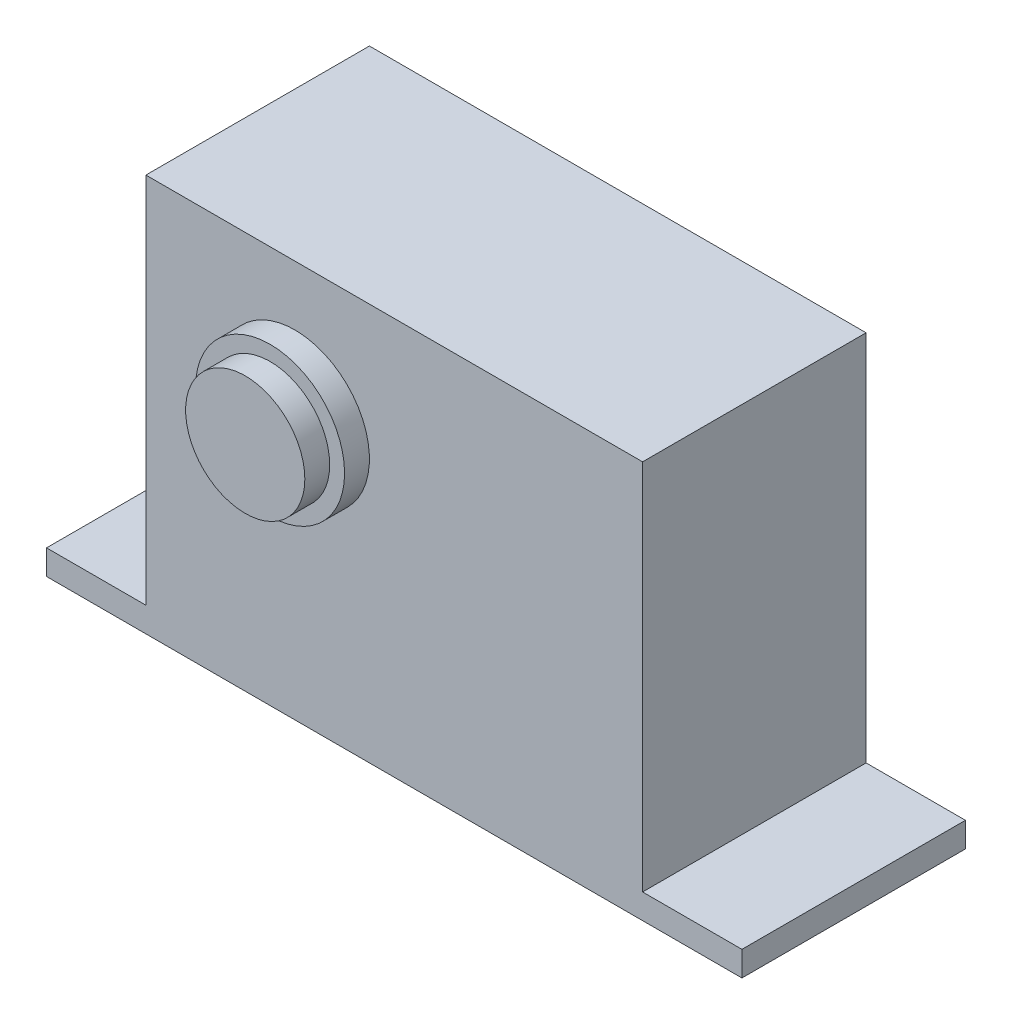
from build123d import *

# Parameters (mm, degrees)
SKETCH1_W           = 70
SKETCH1_H           = 40
BOSS_EXTRUDE1_DEPTH = 22.5
SKETCH2_R           = 7.5
BOSS_EXTRUDE2_DEPTH = 2.5
SKETCH3_R           = 6
BOSS_EXTRUDE3_DEPTH = 2.5
SKETCH4_W           = 22.5
SKETCH4_H           = 37.5
CUT_EXTRUDE1_DEPTH  = 10
SKETCH5_W           = 22.5
SKETCH5_H           = 37.5
CUT_EXTRUDE2_DEPTH  = 10


with BuildPart() as part:
    # Sketch1 → Boss-Extrude1 (new body)
    with BuildSketch(Plane.XY):
        with Locations((35, 20)):
            Rectangle(SKETCH1_W, SKETCH1_H)
    extrude(amount=BOSS_EXTRUDE1_DEPTH)

    # Sketch2 → Boss-Extrude2 (add)
    with BuildSketch(Plane.XY.offset(22.5)):
        with Locations((25, 26.5)):
            Circle(SKETCH2_R)
    extrude(amount=BOSS_EXTRUDE2_DEPTH)

    # Sketch3 → Boss-Extrude3 (add)
    with BuildSketch(Plane.XY.offset(25)):
        with Locations((25, 26.5)):
            Circle(SKETCH3_R)
    extrude(amount=BOSS_EXTRUDE3_DEPTH)

    # Sketch4 → Cut-Extrude1 (cut)
    with BuildSketch(Plane.ZY):
        with Locations((11.25, 21.25)):
            Rectangle(SKETCH4_W, SKETCH4_H)
    extrude(amount=-CUT_EXTRUDE1_DEPTH, mode=Mode.SUBTRACT)

    # Sketch5 → Cut-Extrude2 (cut)
    with BuildSketch(Plane(origin=(70, 0, 0), x_dir=(0, 0, -1), z_dir=(1, 0, 0))):
        with Locations((-11.25, 21.25)):
            Rectangle(SKETCH5_W, SKETCH5_H)
    extrude(amount=-CUT_EXTRUDE2_DEPTH, mode=Mode.SUBTRACT)


solid = part.part
